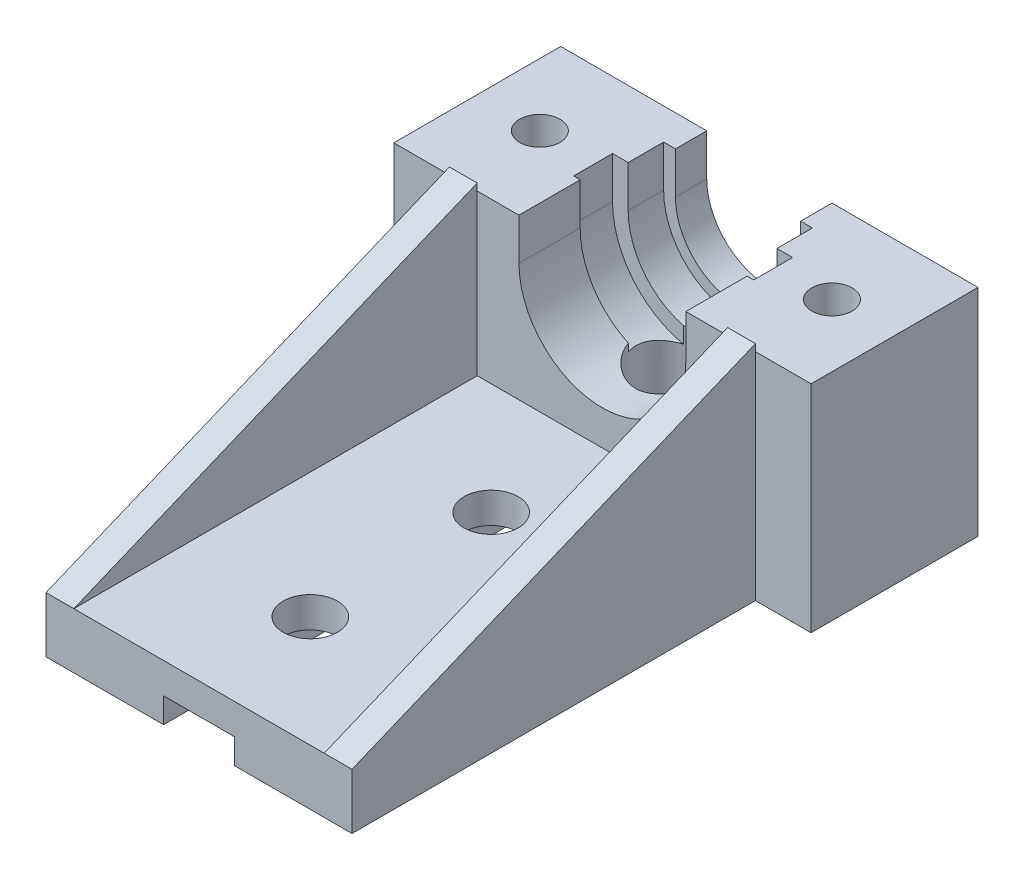
from build123d import *

# Parameters (mm, degrees)
BOSS_EXTRUDE1_DEPTH = 12
CUT_EXTRUDE1_DEPTH  = 9.75
CUT_EXTRUDE4_START  = -4.4
CUT_EXTRUDE4_DEPTH  = 2.8
SKETCH3_R           = 1.45
CUT_EXTRUDE2_DEPTH  = 18
BOSS_EXTRUDE2_DEPTH = 29
SKETCH5_R           = 1.95
SKETCH5_R_2         = 2.6
CUT_EXTRUDE3_DEPTH  = 14.5
BOSS_EXTRUDE3_DEPTH = 2
BOSS_EXTRUDE4_START = -22
BOSS_EXTRUDE4_DEPTH = 2
CUT_EXTRUDE5_DEPTH  = 5.2
SKETCH9_W           = 30
SKETCH9_H           = 12
CUT_EXTRUDE6_DEPTH  = 0.5


with BuildPart() as part:
    # Sketch1 → Boss-Extrude1 (new body)
    with BuildSketch(Plane.XY):
        with BuildLine():
            Line((-5.280588843, 25), (-5.280588843, 41))
            Line((-5.280588843, 41), (5.219411157, 41))
            Line((5.219411157, 41), (5.219411157, 37.5))
            ThreePointArc((5.219411157, 37.5), (9.719411157, 33), (14.219411157, 37.5))
            Line((14.219411157, 37.5), (14.219411157, 41))
            Line((14.219411157, 41), (24.719411157, 41))
            Line((24.719411157, 41), (24.719411157, 25))
            Line((24.719411157, 25), (12.269411157, 25))
            Line((12.269411157, 25), (12.269411157, 26.8))
            Line((12.269411157, 26.8), (7.169411157, 26.8))
            Line((7.169411157, 26.8), (7.169411157, 25))
            Line((7.169411157, 25), (-5.280588843, 25))
        make_face()
    extrude(amount=-BOSS_EXTRUDE1_DEPTH)

    # Sketch2 → Cut-Extrude1 (cut)
    with BuildSketch(Plane.XY):
        with BuildLine():
            Line((4.369411157, 37.5), (4.369411157, 41))
            Line((4.369411157, 41), (15.069411157, 41))
            Line((15.069411157, 41), (15.069411157, 37.5))
            ThreePointArc((15.069411157, 37.5), (9.719411157, 32.15), (4.369411157, 37.5))
        make_face()
    extrude(amount=-CUT_EXTRUDE1_DEPTH, mode=Mode.SUBTRACT)

    # Sketch7 → Cut-Extrude4 (cut)
    with BuildSketch(Plane.XY.offset(CUT_EXTRUDE4_START)):
        with BuildLine():
            Line((3.244411157, 37.5), (3.244411157, 41))
            Line((3.244411157, 41), (16.194411157, 41))
            Line((16.194411157, 41), (16.194411157, 37.5))
            ThreePointArc((16.194411157, 37.5), (9.719411157, 31.025), (3.244411157, 37.5))
        make_face()
    extrude(amount=-CUT_EXTRUDE4_DEPTH, mode=Mode.SUBTRACT)

    # Sketch3 → Cut-Extrude2 (cut)
    with BuildSketch(Plane(origin=(0, 41, 0), x_dir=(1, 0, 0), z_dir=(0, 1, 0))):
        with Locations((20.219411157, 6)):
            Circle(SKETCH3_R)
        with Locations((-0.780588843, 6)):
            Circle(SKETCH3_R)
    extrude(amount=-CUT_EXTRUDE2_DEPTH, mode=Mode.SUBTRACT)

    # Sketch4 → Boss-Extrude2 (add)
    with BuildSketch(Plane.XY):
        Polygon((-1.280588843, 25), (-1.280588843, 29), (20.719411157, 29), (20.719411157, 25), (12.269411157, 25), (12.269411157, 26.8), (7.169411157, 26.8), (7.169411157, 25), align=None)
    extrude(amount=BOSS_EXTRUDE2_DEPTH)

    # Sketch5 → Cut-Extrude3 (cut, symmetric)
    with BuildSketch(Plane(origin=(0, 29, 0), x_dir=(1, 0, 0), z_dir=(0, 1, 0))):
        with Locations((9.719411157, -21)):
            Circle(SKETCH5_R)
        with Locations((9.719411157, -8)):
            Circle(SKETCH5_R)
        with Locations((9.719411157, 5)):
            Circle(SKETCH5_R_2)
    extrude(amount=CUT_EXTRUDE3_DEPTH, both=True, mode=Mode.SUBTRACT)

    # Sketch6 → Boss-Extrude3 (add)
    with BuildSketch(Plane.ZY.offset(1.280588843)):
        Polygon((29, 29), (0, 41), (0, 29), align=None)
    extrude(amount=-BOSS_EXTRUDE3_DEPTH)

    # Sketch6_2 → Boss-Extrude4 (add)
    with BuildSketch(Plane.ZY.offset(1.280588843).offset(BOSS_EXTRUDE4_START)):
        Polygon((29, 29), (0, 41), (0, 29), align=None)
    extrude(amount=BOSS_EXTRUDE4_DEPTH)

    # Sketch8 → Cut-Extrude5 (cut)
    with BuildSketch(Plane.XY):
        with BuildLine():
            Line((3.719411157, 37.5), (3.719411157, 41))
            Line((3.719411157, 41), (15.719411157, 41))
            Line((15.719411157, 41), (15.719411157, 37.5))
            ThreePointArc((15.719411157, 37.5), (9.719411157, 31.5), (3.719411157, 37.5))
        make_face()
    extrude(amount=-CUT_EXTRUDE5_DEPTH, mode=Mode.SUBTRACT)

    # Sketch9 → Cut-Extrude6 (cut)
    with BuildSketch(Plane(origin=(0, 41, 0), x_dir=(1, 0, 0), z_dir=(0, 1, 0))):
        with Locations((9.719411157, 6)):
            Rectangle(SKETCH9_W, SKETCH9_H)
    extrude(amount=-CUT_EXTRUDE6_DEPTH, mode=Mode.SUBTRACT)


solid = part.part
